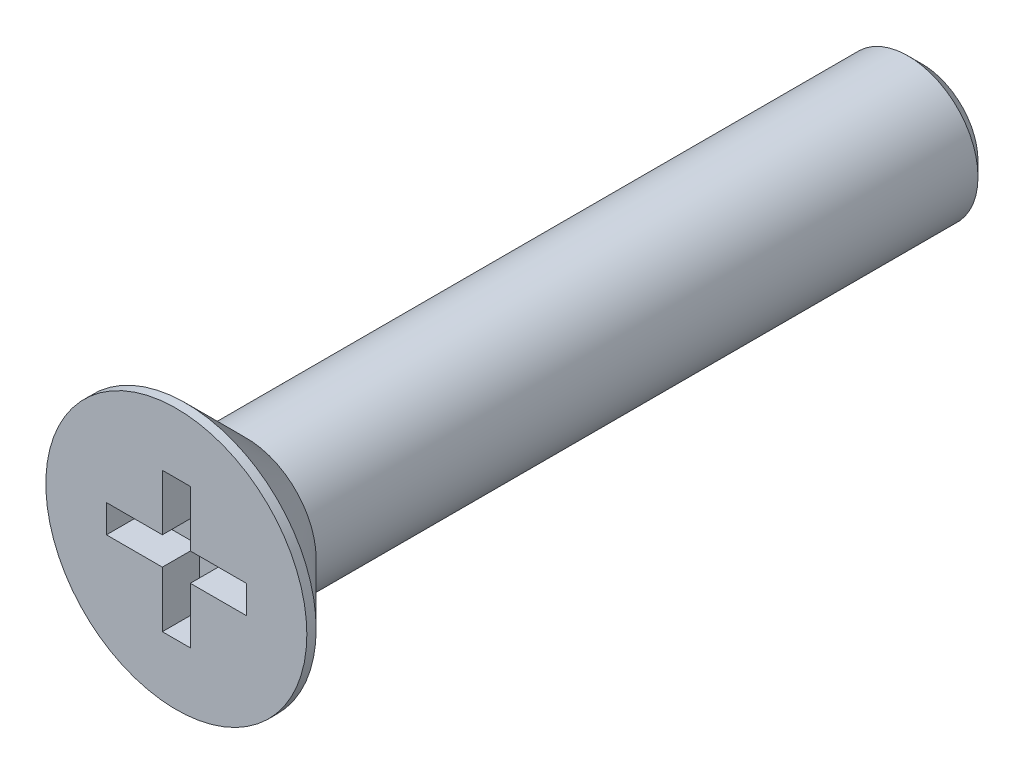
from build123d import *

# Parameters (mm, degrees)
SCHNITT_LINEAR_AUSTRAGEN1_DEPTH = 0.8
FASE1_SIZE                      = 0.3


with BuildPart() as part:
    # Skizze1 → Rotation1 (revolve)
    with BuildSketch(Plane(origin=(0, 0, 0), x_dir=(0, 0, -1), z_dir=(1, 0, 0))):
        Polygon((0, 0), (0, 2.8), (0.2, 2.8), (1.5, 1.5), (16, 1.5), (16, 0), align=None)
    revolve(axis=Axis((0, 0, 31.763581507), (0, 0, -1)))

    # Skizze3 → Schnitt-Linear austragen1 (cut)
    with BuildSketch(Plane.XY):
        Polygon((-1.5, -0.3), (-1.5, 0.3), (-0.3, 0.3), (-0.3, 1.5), (0.3, 1.5), (0.3, 0.3), (1.5, 0.3), (1.5, -0.3), (0.3, -0.3), (0.3, -1.5), (-0.3, -1.5), (-0.3, -0.3), align=None)
    extrude(amount=-SCHNITT_LINEAR_AUSTRAGEN1_DEPTH, mode=Mode.SUBTRACT)

    # Fase1
    fase1_edges = [part.edges().sort_by_distance(p)[0] for p in [
        (0, -1.5, -16),
    ]]
    chamfer(fase1_edges, length=FASE1_SIZE)


solid = part.part
